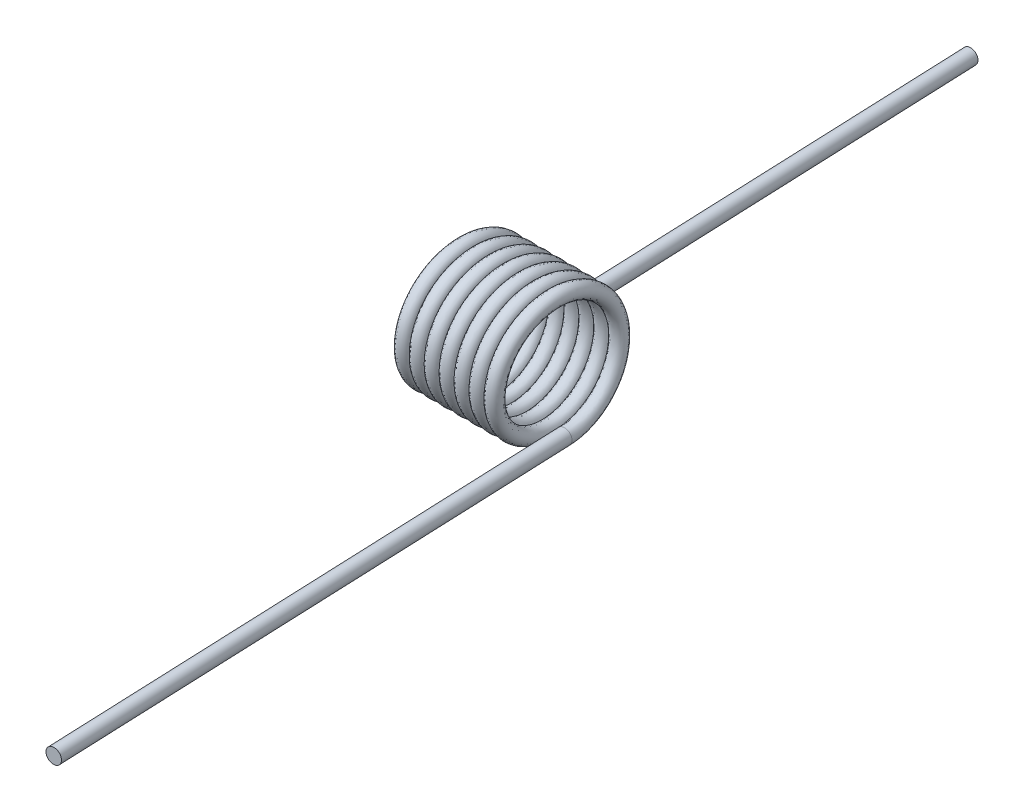
from build123d import *

# Parameters (mm, degrees)
SWEEP1_PITCH       = 0.5344
SWEEP1_HEIGHT      = 3.7408
SWEEP1_RADIUS      = 2.0955
SWEEP1_START_ANGLE = 90
SKETCH2_R          = 0.2667
SKETCH3_R          = 0.2667
EXTRUDE1_DEPTH     = 19.05
SKETCH4_R          = 0.2667
EXTRUDE2_DEPTH     = 19.05


with BuildPart() as part:
    # Sweep1: sweep along a helix
    with BuildLine() as sweep1_path:
        add(Helix(SWEEP1_PITCH, SWEEP1_HEIGHT, SWEEP1_RADIUS, center=(0, 0, 0), direction=(1, 0, 0), lefthand=True, mode=Mode.PRIVATE).rotate(Axis((0, 0, 0), (1, 0, 0)), SWEEP1_START_ANGLE))
    # Sketch2 → Sweep1 (sweep)
    with BuildSketch(Plane(origin=(0, -2.0955, 0), x_dir=(0.999177319, 0, -0.040554727), z_dir=(0.040554727, 0, 0.999177319))):
        Circle(SKETCH2_R)
    sweep(path=sweep1_path.line, is_frenet=True)

    # Sketch3 → Extrude1 (add)
    with BuildSketch(Plane(origin=(0, 0, 0), x_dir=(-0.999177319, 0, 0.040554727), z_dir=(-0.040554727, 0, -0.999177319))):
        with Locations((0, -2.0955)):
            Circle(SKETCH3_R)
    extrude(amount=EXTRUDE1_DEPTH)

    # Sketch4 → Extrude2 (add)
    with BuildSketch(Plane(origin=(0.006152441, 0, 0.151582316), x_dir=(0.995509646, -0.085603214, -0.040405863), z_dir=(0.040554727, 0, 0.999177319))):
        with Locations((3.90338402, -1.767847005)):
            Circle(SKETCH4_R)
    extrude(amount=EXTRUDE2_DEPTH)


solid = part.part
